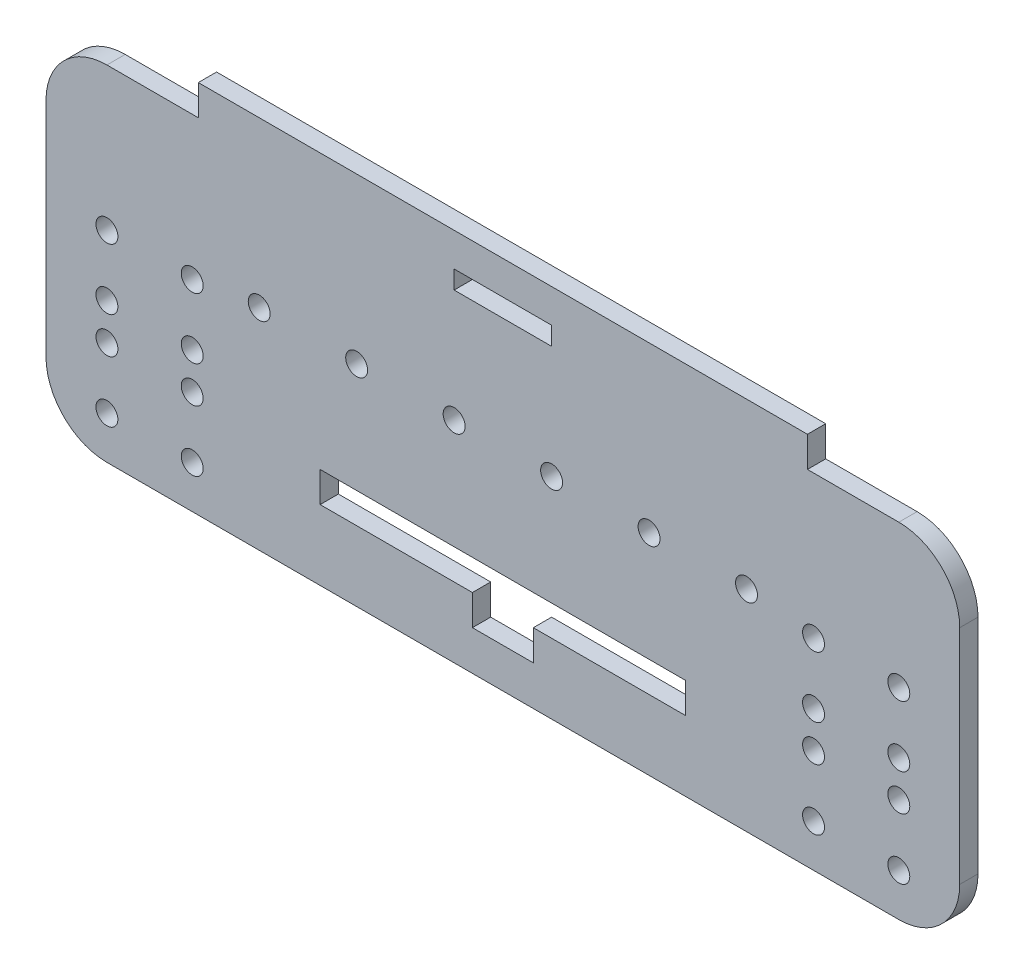
from build123d import *

# Parameters (mm, degrees)
BOSS_EXTRUDE1_DEPTH = 3
SKETCH2_R           = 1.8
SKETCH2_W           = 60
SKETCH2_H           = 5
SKETCH2_W_2         = 16
SKETCH2_H_2         = 3
CUT_EXTRUDE1_DEPTH  = 5
SKETCH3_W           = 10
SKETCH3_H           = 5
CUT_EXTRUDE2_DEPTH  = 10


with BuildPart() as part:
    # Sketch1 → Boss-Extrude1 (new body)
    with BuildSketch(Plane.XY):
        with BuildLine():
            Line((-65, 28.25), (-50, 28.25))
            Line((-50, 28.25), (-50, 33.25))
            Line((-50, 33.25), (50, 33.25))
            Line((50, 33.25), (50, 28.25))
            Line((50, 28.25), (65, 28.25))
            ThreePointArc((65, 28.25), (72.071067812, 25.321067812), (75, 18.25))
            Line((75, 18.25), (75, -18.25))
            ThreePointArc((75, -18.25), (72.071067812, -25.321067812), (65, -28.25))
            Line((65, -28.25), (-65, -28.25))
            ThreePointArc((-65, -28.25), (-72.071067812, -25.321067812), (-75, -18.25))
            Line((-75, -18.25), (-75, 18.25))
            ThreePointArc((-75, 18.25), (-72.071067812, 25.321067812), (-65, 28.25))
        make_face()
    extrude(amount=BOSS_EXTRUDE1_DEPTH)

    # Sketch2 → Cut-Extrude1 (cut)
    with BuildSketch(Plane.XY.offset(3)):
        with Locations((-65, -21.25)):
            Circle(SKETCH2_R)
        with Locations((-65, -11.25)):
            Circle(SKETCH2_R)
        with Locations((-65, -5.25)):
            Circle(SKETCH2_R)
        with Locations((-51, -5.25)):
            Circle(SKETCH2_R)
        with Locations((-51, -11.25)):
            Circle(SKETCH2_R)
        with Locations((-51, -21.25)):
            Circle(SKETCH2_R)
        with Locations((51, -5.25)):
            Circle(SKETCH2_R)
        with Locations((51, -11.25)):
            Circle(SKETCH2_R)
        with Locations((51, -21.25)):
            Circle(SKETCH2_R)
        with Locations((65, -21.25)):
            Circle(SKETCH2_R)
        with Locations((65, -11.25)):
            Circle(SKETCH2_R)
        with Locations((65, -5.25)):
            Circle(SKETCH2_R)
        with Locations((-65, 4.75)):
            Circle(SKETCH2_R)
        with Locations((-51, 4.75)):
            Circle(SKETCH2_R)
        with Locations((65, 4.75)):
            Circle(SKETCH2_R)
        with Locations((51, 4.75)):
            Circle(SKETCH2_R)
        with Locations((24, 6.25)):
            Circle(SKETCH2_R)
        with Locations((40, 6.25)):
            Circle(SKETCH2_R)
        with Locations((-40, 6.25)):
            Circle(SKETCH2_R)
        with Locations((-24, 6.25)):
            Circle(SKETCH2_R)
        with Locations((8, 6.25)):
            Circle(SKETCH2_R)
        with Locations((-8, 6.25)):
            Circle(SKETCH2_R)
        with Locations((0, -14.25)):
            Rectangle(SKETCH2_W, SKETCH2_H)
        with Locations((0, 26.25)):
            Rectangle(SKETCH2_W_2, SKETCH2_H_2)
    extrude(amount=-CUT_EXTRUDE1_DEPTH, mode=Mode.SUBTRACT)

    # Sketch3 → Cut-Extrude2 (cut)
    with BuildSketch(Plane.XY.offset(3)):
        with Locations((0, -19.25)):
            Rectangle(SKETCH3_W, SKETCH3_H)
    extrude(amount=-CUT_EXTRUDE2_DEPTH, mode=Mode.SUBTRACT)


solid = part.part
